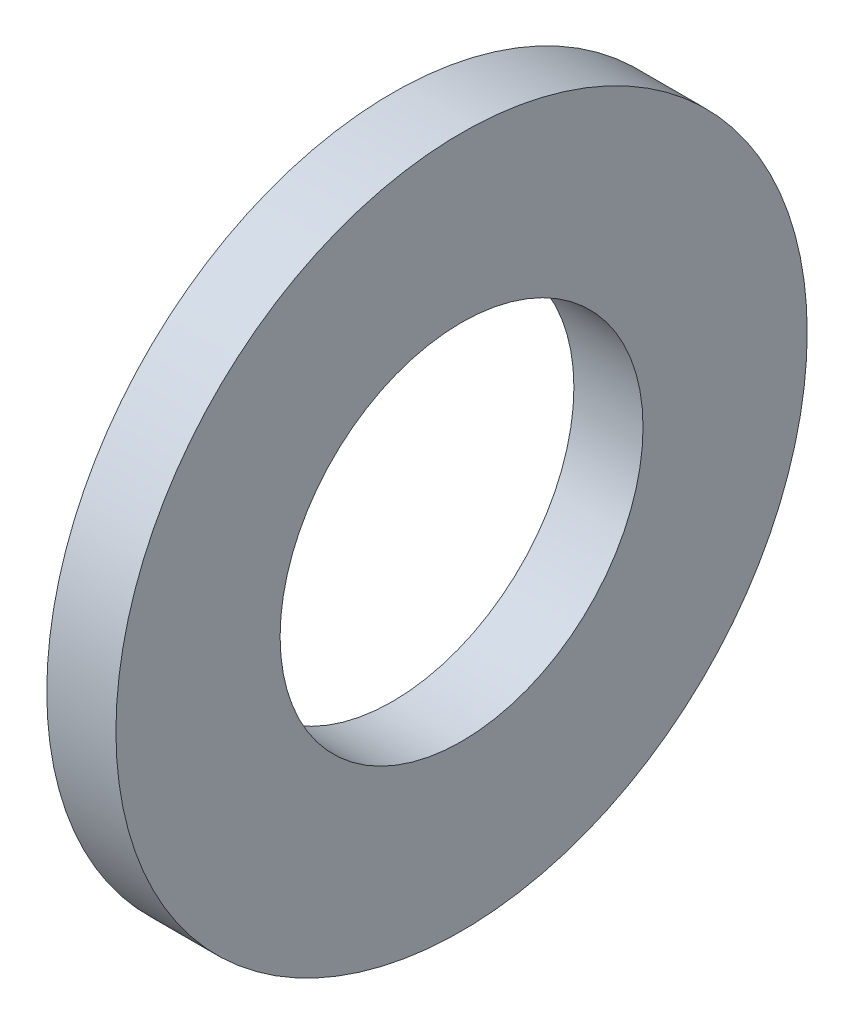
from build123d import *

# Parameters (mm, degrees)
SZKIC1_W = 1.6
SZKIC1_H = 3.8


with BuildPart() as part:
    # Szkic1 → Obrót1 (revolve)
    with BuildSketch(Plane.XY):
        with Locations((0.8, 6.1)):
            Rectangle(SZKIC1_W, SZKIC1_H)
    revolve(axis=Axis((0, 0, 0), (1, 0, 0)))


solid = part.part
